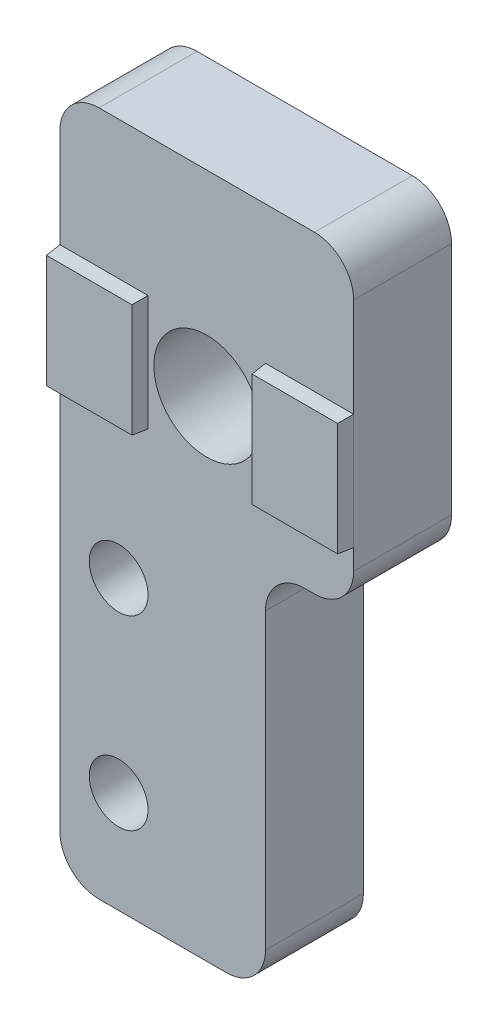
from build123d import *

# Parameters (mm, degrees)
SKETCH1_R           = 2.7
SKETCH1_R_2         = 1.5
BOSS_EXTRUDE1_DEPTH = 5
SKETCH2_W           = 4.5
SKETCH2_H           = 5.9
BOSS_EXTRUDE2_DEPTH = 0.75
BOSS_EXTRUDE2_TAPER = 5


with BuildPart() as part:
    # Sketch1 → Boss-Extrude1 (new body)
    with BuildSketch(Plane.XY):
        with BuildLine():
            Line((0, -2), (0, -33))
            ThreePointArc((0, -33), (0.585786438, -34.414213562), (2, -35))
            Line((2, -35), (8.5, -35))
            ThreePointArc((8.5, -35), (9.914213562, -34.414213562), (10.5, -33))
            Line((10.5, -33), (10.5, -18))
            ThreePointArc((10.5, -18), (11.085786438, -16.585786438), (12.5, -16))
            Line((12.5, -16), (13, -16))
            ThreePointArc((13, -16), (14.414213562, -15.414213562), (15, -14))
            Line((15, -14), (15, -2))
            ThreePointArc((15, -2), (14.414213562, -0.585786438), (13, 0))
            Line((13, 0), (2, 0))
            ThreePointArc((2, 0), (0.585786438, -0.585786438), (0, -2))
        make_face()
        with Locations((7.5, -10)):
            Circle(SKETCH1_R, mode=Mode.SUBTRACT)
        with Locations((3, -29.8)):
            Circle(SKETCH1_R_2, mode=Mode.SUBTRACT)
        with Locations((3, -20.3)):
            Circle(SKETCH1_R_2, mode=Mode.SUBTRACT)
    extrude(amount=BOSS_EXTRUDE1_DEPTH)

    # Sketch2 → Boss-Extrude2 (add)
    with BuildSketch(Plane.XY.offset(5)):
        with Locations((2.25, -10)):
            Rectangle(SKETCH2_W, SKETCH2_H)
        with Locations((12.75, -10)):
            Rectangle(SKETCH2_W, SKETCH2_H)
    extrude(amount=BOSS_EXTRUDE2_DEPTH, taper=BOSS_EXTRUDE2_TAPER)


solid = part.part
